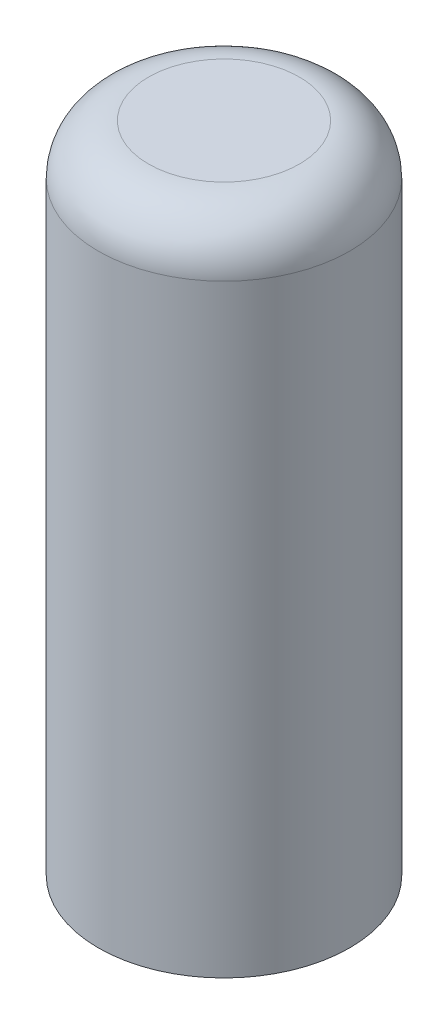
from build123d import *

# Parameters (mm, degrees)
SKETCH2_R           = 2.5
SKETCH2_W           = 1.15
SKETCH2_H           = 1.2
BOSS_EXTRUDE1_DEPTH = 6.5
FILLET1_R           = 1
SKETCH3_W           = 1.15
SKETCH3_H           = 1.2
BOSS_EXTRUDE5_DEPTH = 1


with BuildPart() as part:
    # Sketch2 → Boss-Extrude1 (new body, symmetric)
    with BuildSketch(Plane(origin=(0, 0, 0), x_dir=(1, 0, 0), z_dir=(0, 1, 0))):
        Circle(SKETCH2_R)
        Rectangle(SKETCH2_W, SKETCH2_H, mode=Mode.SUBTRACT)
    extrude(amount=BOSS_EXTRUDE1_DEPTH, both=True)

    # Fillet1
    fillet1_edges = [part.edges().sort_by_distance(p)[0] for p in [
        (-2.5, 6.5, 0),
    ]]
    fillet(fillet1_edges, radius=FILLET1_R)

    # Sketch3 → Boss-Extrude5 (add)
    with BuildSketch(Plane(origin=(0, 6.5, 0), x_dir=(1, 0, 0), z_dir=(0, 1, 0))):
        Rectangle(SKETCH3_W, SKETCH3_H)
    extrude(amount=-BOSS_EXTRUDE5_DEPTH)


solid = part.part
